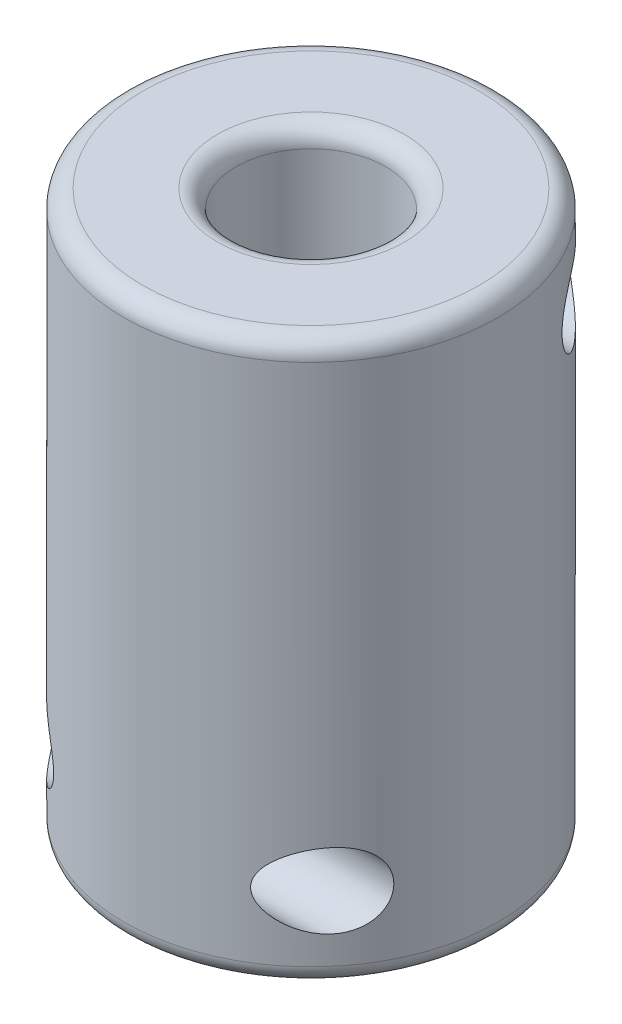
from build123d import *

# Parameters (mm, degrees)
SKETCH1_R               = 10
SKETCH1_R_2             = 4
BOSS_EXTRUDE1_DEPTH     = 30
SKETCH2_R               = 2
CUT_EXTRUDE1_DEPTH      = 11
CUT_EXTRUDE1_DEPTH_BACK = 11
FILLET1_R               = 1


with BuildPart() as part:
    # Sketch1 → Boss-Extrude1 (new body)
    with BuildSketch(Plane(origin=(0, 0, 0), x_dir=(1, 0, 0), z_dir=(0, 1, 0))):
        Circle(SKETCH1_R)
        Circle(SKETCH1_R_2, mode=Mode.SUBTRACT)
    extrude(amount=BOSS_EXTRUDE1_DEPTH)

    # Sketch2 → Cut-Extrude1 (cut, two sides)
    with BuildSketch(Plane(origin=(0, 0, 0), x_dir=(0, 0, -1), z_dir=(1, 0, 0))) as cut_extrude1_sk:
        with Locations((6.5, 25.5)):
            Circle(SKETCH2_R)
        with Locations((-6.5, 4.5)):
            Circle(SKETCH2_R)
    extrude(amount=CUT_EXTRUDE1_DEPTH, mode=Mode.SUBTRACT)
    extrude(cut_extrude1_sk.sketch, amount=-CUT_EXTRUDE1_DEPTH_BACK, mode=Mode.SUBTRACT)

    # Fillet1
    fillet1_edges = [part.edges().sort_by_distance(p)[0] for p in [
        (-10, 0, 0),
        (-10, 30, 0),
        (-4, 0, 0),
        (-4, 30, 0),
    ]]
    fillet(fillet1_edges, radius=FILLET1_R)


solid = part.part
